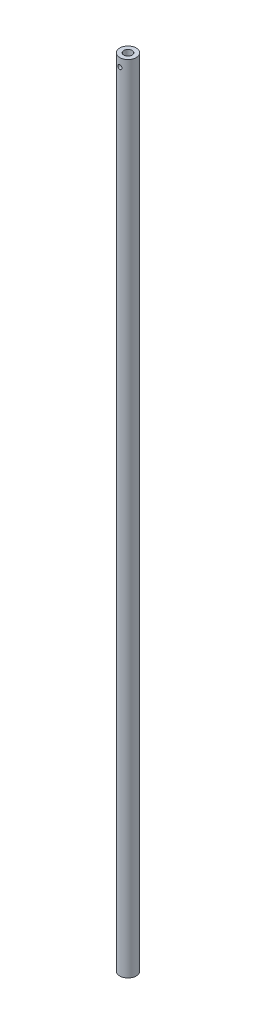
from build123d import *

# Parameters (mm, degrees)
SKETCH1_R           = 12.7
SKETCH1_R_2         = 6.35
BOSS_EXTRUDE2_DEPTH = 1219.2
SKETCH2_R           = 3.175
CUT_EXTRUDE1_DEPTH  = 39.1


with BuildPart() as part:
    # Sketch1 → Boss-Extrude2 (new body)
    with BuildSketch(Plane(origin=(0, 0, 0), x_dir=(1, 0, 0), z_dir=(0, 1, 0))):
        Circle(SKETCH1_R)
        Circle(SKETCH1_R_2, mode=Mode.SUBTRACT)
    extrude(amount=BOSS_EXTRUDE2_DEPTH)

    # Sketch2 → Cut-Extrude1 (cut, through all)
    with BuildSketch(Plane.XY.offset(25.4)):
        with Locations((0, 1206.5)):
            Circle(SKETCH2_R)
    extrude(amount=-CUT_EXTRUDE1_DEPTH, mode=Mode.SUBTRACT)


solid = part.part
